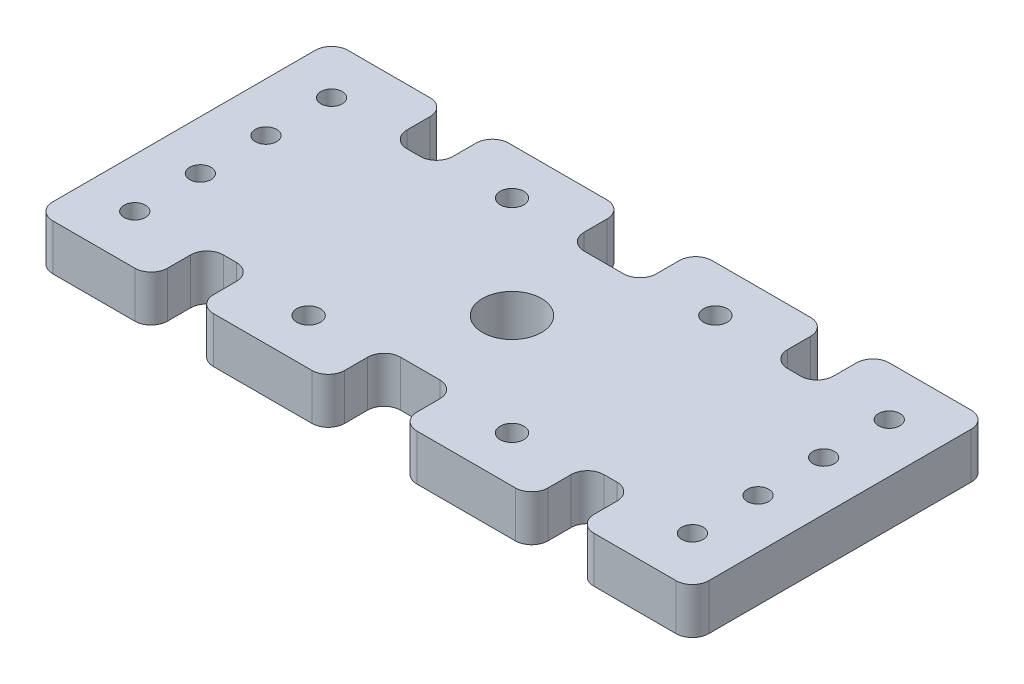
from build123d import *

# Parameters (mm, degrees)
SKETCH1_W             = 100
SKETCH1_H             = 45
BOSS_EXTRUDE1_DEPTH   = 7
M3_CLEARANCE_HOLE1_D  = 3.6
M8_CLEARANCE_HOLE1_D  = 9
F_4_CLEARANCE_HOLE1_D = 3.2639
LPATTERN1_COUNT       = 4
LPATTERN1_PITCH       = 10
MIRROR1_COPY_1_D      = 3.2639
MIRROR1_COPY_2_D      = 3.2639
MIRROR1_COPY_3_D      = 3.2639
SKETCH9_W             = 7
SKETCH9_H             = 8.5
SKETCH9_W_2           = 11
CUT_EXTRUDE1_DEPTH    = 8
FILLET1_R             = 2.5


with BuildPart() as part:
    # Sketch1 → Boss-Extrude1 (new body)
    with BuildSketch(Plane(origin=(0, 0, 0), x_dir=(1, 0, 0), z_dir=(0, 1, 0))):
        Rectangle(SKETCH1_W, SKETCH1_H)
    extrude(amount=BOSS_EXTRUDE1_DEPTH)

    # M3 Clearance Hole1 (through all)
    with Locations(Plane(origin=(0, 7, 0), x_dir=(1, 0, 0), z_dir=(0, 1, 0))):
        with Locations((15.5, 15.5), (-15.5, 15.5), (-15.5, -15.5), (15.5, -15.5)):
            Hole(M3_CLEARANCE_HOLE1_D / 2)

    # M8 Clearance Hole1 (through all)
    with Locations(Plane(origin=(0, 7, 0), x_dir=(1, 0, 0), z_dir=(0, 1, 0))):
        with Locations((0, 0)):
            Hole(M8_CLEARANCE_HOLE1_D / 2)

    # #4 Clearance Hole1 (through all)
    with Locations(Plane(origin=(0, 7, 0), x_dir=(1, 0, 0), z_dir=(0, 1, 0))):
        with Locations((-42.5, 15)):
            f_4_clearance_hole1 = Hole(F_4_CLEARANCE_HOLE1_D / 2)

    # LPattern1: #4 Clearance Hole1 ×4
    with Locations(*[(0, 0, i * LPATTERN1_PITCH) for i in range(1, LPATTERN1_COUNT)]):
        add(f_4_clearance_hole1, mode=Mode.SUBTRACT)

    # Mirror1: #4 Clearance Hole1 across plane
    add(f_4_clearance_hole1.mirror(Plane(origin=(0, 0, 0), x_dir=(0, 0, 1), z_dir=(1, 0, 0))), mode=Mode.SUBTRACT)

    # Mirror1 copy 1 (through all)
    with Locations(Plane(origin=(0, 7, 10), x_dir=(-1, 0, 0), z_dir=(0, 1, 0))):
        with Locations((-42.5, -15)):
            Hole(MIRROR1_COPY_1_D / 2)

    # Mirror1 copy 2 (through all)
    with Locations(Plane(origin=(0, 7, 20), x_dir=(-1, 0, 0), z_dir=(0, 1, 0))):
        with Locations((-42.5, -15)):
            Hole(MIRROR1_COPY_2_D / 2)

    # Mirror1 copy 3 (through all)
    with Locations(Plane(origin=(0, 7, 30), x_dir=(-1, 0, 0), z_dir=(0, 1, 0))):
        with Locations((-42.5, -15)):
            Hole(MIRROR1_COPY_3_D / 2)

    # Sketch9 → Cut-Extrude1 (cut, through all)
    with BuildSketch(Plane(origin=(0, 7, 0), x_dir=(1, 0, 0), z_dir=(0, 1, 0))):
        with Locations((-29, 18.25)):
            Rectangle(SKETCH9_W, SKETCH9_H)
        with Locations((-29, -18.25)):
            Rectangle(SKETCH9_W, SKETCH9_H)
        with Locations((29, -18.25)):
            Rectangle(SKETCH9_W, SKETCH9_H)
        with Locations((29, 18.25)):
            Rectangle(SKETCH9_W, SKETCH9_H)
        with Locations((0, 18.25)):
            Rectangle(SKETCH9_W_2, SKETCH9_H)
        with Locations((0, -18.25)):
            Rectangle(SKETCH9_W_2, SKETCH9_H)
    extrude(amount=-CUT_EXTRUDE1_DEPTH, mode=Mode.SUBTRACT)

    # Fillet1
    fillet1_edges = [part.edges().sort_by_distance(p)[0] for p in [
        (5.5, 3.5, 22.5),
        (-5.5, 3.5, 22.5),
        (-5.5, 3.5, 14),
        (5.5, 3.5, 14),
        (25.5, 3.5, -22.5),
        (32.5, 3.5, -22.5),
        (32.5, 3.5, -14),
        (25.5, 3.5, -14),
        (32.5, 3.5, 22.5),
        (25.5, 3.5, 22.5),
        (25.5, 3.5, 14),
        (32.5, 3.5, 14),
        (-25.5, 3.5, 22.5),
        (-32.5, 3.5, 22.5),
        (-32.5, 3.5, 14),
        (-25.5, 3.5, 14),
        (5.5, 3.5, -22.5),
        (5.5, 3.5, -14),
        (-5.5, 3.5, -14),
        (-5.5, 3.5, -22.5),
        (-32.5, 3.5, -22.5),
        (-25.5, 3.5, -22.5),
        (-25.5, 3.5, -14),
        (-32.5, 3.5, -14),
        (-50, 3.5, -22.5),
        (50, 3.5, -22.5),
        (50, 3.5, 22.5),
        (-50, 3.5, 22.5),
    ]]
    fillet(fillet1_edges, radius=FILLET1_R)


solid = part.part
